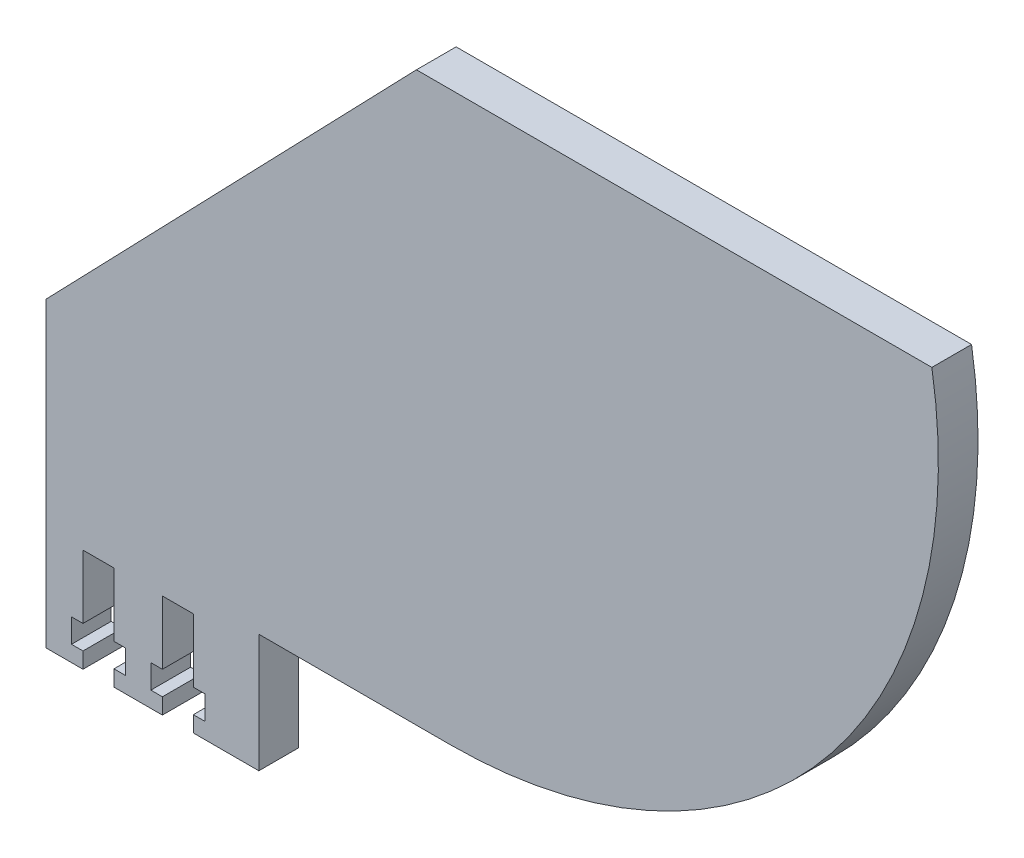
from build123d import *

# Parameters (mm, degrees)
BOSS_EXTRUDE1_DEPTH = 5
CUT_EXTRUDE1_DEPTH  = 5


with BuildPart() as part:
    # Sketch2 → Boss-Extrude1 (new body)
    with BuildSketch(Plane.XY):
        with BuildLine():
            Line((-227.482425682, -83.89157587), (-200.672425682, -83.89157587))
            Line((-200.672425682, -83.89157587), (-200.672425682, -68.99157587))
            Line((-200.672425682, -68.99157587), (-176.574253233, -68.99157587))
            ThreePointArc((-176.574253233, -68.99157587), (-129.684755475, -47.286361961), (-115.892707438, 2.50842413))
            Line((-115.892707438, 2.50842413), (-180.821327591, 2.50842413))
            Line((-180.821327591, 2.50842413), (-227.482425682, -45.84868874))
            Line((-227.482425682, -45.84868874), (-227.482425682, -83.89157587))
        make_face()
    extrude(amount=BOSS_EXTRUDE1_DEPTH)

    # Sketch4 → Cut-Extrude1 (cut)
    with BuildSketch(Plane.XY.offset(5)):
        Polygon((-212.822425682, -83.89157587), (-208.922425682, -83.89157587), (-208.922425682, -81.89157587), (-207.472425682, -81.89157587), (-207.472425682, -78.89157587), (-208.922425682, -78.89157587), (-208.922425682, -70.89157587), (-212.822425682, -70.89157587), (-212.822425682, -78.89157587), (-214.272425682, -78.89157587), (-214.272425682, -81.89157587), (-212.822425682, -81.89157587), align=None)
        Polygon((-222.822425682, -83.89157587), (-218.922425682, -83.89157587), (-218.922425682, -81.89157587), (-217.472425682, -81.89157587), (-217.472425682, -78.89157587), (-218.922425682, -78.89157587), (-218.922425682, -70.89157587), (-222.822425682, -70.89157587), (-222.822425682, -78.89157587), (-224.272425682, -78.89157587), (-224.272425682, -81.89157587), (-222.822425682, -81.89157587), align=None)
    extrude(amount=-CUT_EXTRUDE1_DEPTH, mode=Mode.SUBTRACT)


solid = part.part
